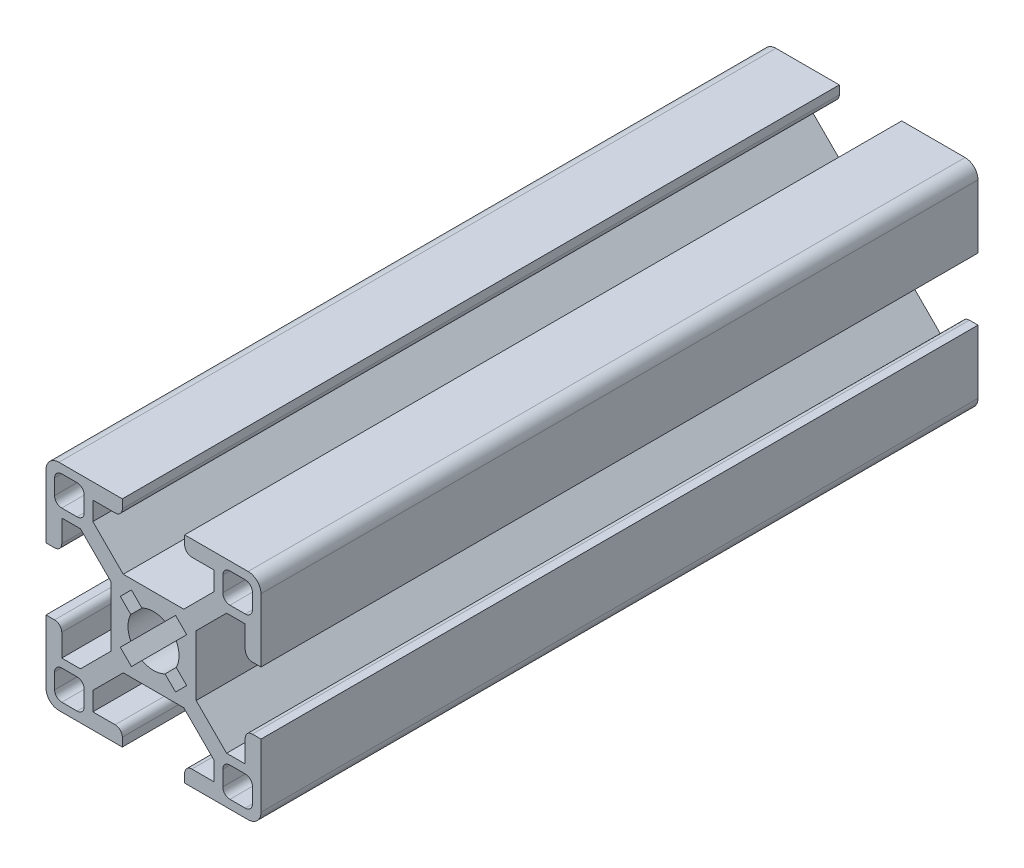
from build123d import *

# Parameters (mm, degrees)
SKETCH1_W           = 11.9
SKETCH1_H           = 5.95
BOSS_EXTRUDE1_DEPTH = 100
CUT_EXTRUDE1_DEPTH  = 101


with BuildPart() as part:
    # Sketch1 → Boss-Extrude1 (new body)
    with BuildSketch(Plane.XY):
        with BuildLine():
            Line((-4.350229073, 14.992640687), (-13.192640687, 14.992640687))
            ThreePointArc((-13.192640687, 14.992640687), (-14.465432893, 14.465432893), (-14.992640687, 13.192640687))
            Line((-14.992640687, 13.192640687), (-14.992640687, 4.350229073))
            Line((-14.992640687, 4.350229073), (-13.792640687, 4.350229073))
            ThreePointArc((-13.792640687, 4.350229073), (-13.085533906, 4.643122292), (-12.792640687, 5.350229073))
            Line((-12.792640687, 5.350229073), (-12.792640687, 8.460229073))
            Line((-12.792640687, 8.460229073), (-8.460229073, 8.460229073))
            Line((-8.460229073, 8.460229073), (-8.460229073, 12.792640687))
            Line((-8.460229073, 12.792640687), (-5.350229073, 12.792640687))
            ThreePointArc((-5.350229073, 12.792640687), (-4.643122292, 13.085533906), (-4.350229073, 13.792640687))
            Line((-4.350229073, 13.792640687), (-4.350229073, 14.992640687))
        make_face()
        with BuildLine():
            Line((-10.660229073, 13.792640687), (-12.792640687, 13.792640687))
            ThreePointArc((-12.792640687, 13.792640687), (-13.499747468, 13.499747468), (-13.792640687, 12.792640687))
            Line((-13.792640687, 12.792640687), (-13.792640687, 10.660229073))
            ThreePointArc((-13.792640687, 10.660229073), (-13.499747468, 9.953122292), (-12.792640687, 9.660229073))
            Line((-12.792640687, 9.660229073), (-10.660229073, 9.660229073))
            ThreePointArc((-10.660229073, 9.660229073), (-9.953122292, 9.953122292), (-9.660229073, 10.660229073))
            Line((-9.660229073, 10.660229073), (-9.660229073, 12.792640687))
            ThreePointArc((-9.660229073, 12.792640687), (-9.953122292, 13.499747468), (-10.660229073, 13.792640687))
        make_face(mode=Mode.SUBTRACT)
        Polygon((-5.95, 4.217588386), (-5.95, 5.95), (-4.217588386, 5.95), (-8.460229073, 10.192640687), (-8.460229073, 8.460229073), (-10.192640687, 8.460229073), align=None)
        with Locations((0, 2.975)):
            Rectangle(SKETCH1_W, SKETCH1_H)
        Polygon((8.460229073, 10.192640687), (4.217588386, 5.95), (5.95, 5.95), (5.95, 4.217588386), (10.192640687, 8.460229073), (8.460229073, 8.460229073), align=None)
        with BuildLine():
            Line((12.792640687, 8.460229073), (12.792640687, 5.350229073))
            ThreePointArc((12.792640687, 5.350229073), (13.085533906, 4.643122292), (13.792640687, 4.350229073))
            Line((13.792640687, 4.350229073), (14.992640687, 4.350229073))
            Line((14.992640687, 4.350229073), (14.992640687, 13.192640687))
            ThreePointArc((14.992640687, 13.192640687), (14.465432893, 14.465432893), (13.192640687, 14.992640687))
            Line((13.192640687, 14.992640687), (4.350229073, 14.992640687))
            Line((4.350229073, 14.992640687), (4.350229073, 13.792640687))
            ThreePointArc((4.350229073, 13.792640687), (4.643122292, 13.085533906), (5.350229073, 12.792640687))
            Line((5.350229073, 12.792640687), (8.460229073, 12.792640687))
            Line((8.460229073, 12.792640687), (8.460229073, 8.460229073))
            Line((8.460229073, 8.460229073), (12.792640687, 8.460229073))
        make_face()
        with BuildLine():
            ThreePointArc((9.660229073, 10.660229073), (9.953122292, 9.953122292), (10.660229073, 9.660229073))
            Line((10.660229073, 9.660229073), (12.792640687, 9.660229073))
            ThreePointArc((12.792640687, 9.660229073), (13.499747468, 9.953122292), (13.792640687, 10.660229073))
            Line((13.792640687, 10.660229073), (13.792640687, 12.792640687))
            ThreePointArc((13.792640687, 12.792640687), (13.499747468, 13.499747468), (12.792640687, 13.792640687))
            Line((12.792640687, 13.792640687), (10.660229073, 13.792640687))
            ThreePointArc((10.660229073, 13.792640687), (9.953122292, 13.499747468), (9.660229073, 12.792640687))
            Line((9.660229073, 12.792640687), (9.660229073, 10.660229073))
        make_face(mode=Mode.SUBTRACT)
    extrude(amount=-BOSS_EXTRUDE1_DEPTH)

    # Mirror1: part across plane


with BuildPart() as part_1:
    add(part.part)
    add(part.part.mirror(Plane(origin=(0, 0, -100), x_dir=(0, 0, 1), z_dir=(0, -1, 0))))

    # Sketch2 → Cut-Extrude1 (cut, through all)
    with BuildSketch(Plane.XY):
        with BuildLine():
            Line((-4.631549417, 3.075914498), (-3.16821753, 1.612582612))
            ThreePointArc((-3.16821753, 1.612582612), (-2.513764607, 2.513764607), (-1.612582612, 3.16821753))
            Line((-1.612582612, 3.16821753), (-3.075914498, 4.631549417))
            Line((-3.075914498, 4.631549417), (-4.631549417, 3.075914498))
        make_face()
        with BuildLine():
            Line((-3.16821753, 1.612582612), (-1.555634919, 0))
            Line((-1.555634919, 0), (0, 1.555634919))
            Line((0, 1.555634919), (-1.612582612, 3.16821753))
            ThreePointArc((-1.612582612, 3.16821753), (-2.513764607, 2.513764607), (-3.16821753, 1.612582612))
        make_face()
        with BuildLine():
            ThreePointArc((-3.16821753, 1.612582612), (-3.555, 0), (-3.16821753, -1.612582612))
            Line((-3.16821753, -1.612582612), (-1.555634919, 0))
            Line((-1.555634919, 0), (-3.16821753, 1.612582612))
        make_face()
        with BuildLine():
            Line((-4.631549417, -3.075914498), (-3.075914498, -4.631549417))
            Line((-3.075914498, -4.631549417), (-1.612582612, -3.16821753))
            ThreePointArc((-1.612582612, -3.16821753), (-2.513764607, -2.513764607), (-3.16821753, -1.612582612))
            Line((-3.16821753, -1.612582612), (-4.631549417, -3.075914498))
        make_face()
        with BuildLine():
            ThreePointArc((-3.16821753, -1.612582612), (-2.513764607, -2.513764607), (-1.612582612, -3.16821753))
            Line((-1.612582612, -3.16821753), (0, -1.555634919))
            Line((0, -1.555634919), (-1.555634919, 0))
            Line((-1.555634919, 0), (-3.16821753, -1.612582612))
        make_face()
        with BuildLine():
            Line((0, -1.555634919), (-1.612582612, -3.16821753))
            ThreePointArc((-1.612582612, -3.16821753), (0, -3.555), (1.612582612, -3.16821753))
            Line((1.612582612, -3.16821753), (0, -1.555634919))
        make_face()
        with BuildLine():
            Line((1.555634919, 0), (0, -1.555634919))
            Line((0, -1.555634919), (1.612582612, -3.16821753))
            ThreePointArc((1.612582612, -3.16821753), (2.513764607, -2.513764607), (3.16821753, -1.612582612))
            Line((3.16821753, -1.612582612), (1.555634919, 0))
        make_face()
        with BuildLine():
            Line((3.16821753, 1.612582612), (1.555634919, 0))
            Line((1.555634919, 0), (3.16821753, -1.612582612))
            ThreePointArc((3.16821753, -1.612582612), (3.456952294, -0.829159719), (3.555, 0))
            ThreePointArc((3.555, 0), (3.456952294, 0.829159719), (3.16821753, 1.612582612))
        make_face()
        Polygon((-1.555634919, 0), (0, -1.555634919), (1.555634919, 0), (0, 1.555634919), align=None)
        with BuildLine():
            Line((0, 1.555634919), (1.555634919, 0))
            Line((1.555634919, 0), (3.16821753, 1.612582612))
            ThreePointArc((3.16821753, 1.612582612), (2.513764607, 2.513764607), (1.612582612, 3.16821753))
            Line((1.612582612, 3.16821753), (0, 1.555634919))
        make_face()
        with BuildLine():
            Line((-1.612582612, 3.16821753), (0, 1.555634919))
            Line((0, 1.555634919), (1.612582612, 3.16821753))
            ThreePointArc((1.612582612, 3.16821753), (0, 3.555), (-1.612582612, 3.16821753))
        make_face()
        with BuildLine():
            ThreePointArc((1.612582612, 3.16821753), (2.513764607, 2.513764607), (3.16821753, 1.612582612))
            Line((3.16821753, 1.612582612), (4.631549417, 3.075914498))
            Line((4.631549417, 3.075914498), (3.075914498, 4.631549417))
            Line((3.075914498, 4.631549417), (1.612582612, 3.16821753))
        make_face()
        with BuildLine():
            ThreePointArc((3.16821753, -1.612582612), (2.513764607, -2.513764607), (1.612582612, -3.16821753))
            Line((1.612582612, -3.16821753), (3.075914498, -4.631549417))
            Line((3.075914498, -4.631549417), (4.631549417, -3.075914498))
            Line((4.631549417, -3.075914498), (3.16821753, -1.612582612))
        make_face()
    extrude(amount=-CUT_EXTRUDE1_DEPTH, mode=Mode.SUBTRACT)


solid = part_1.part
